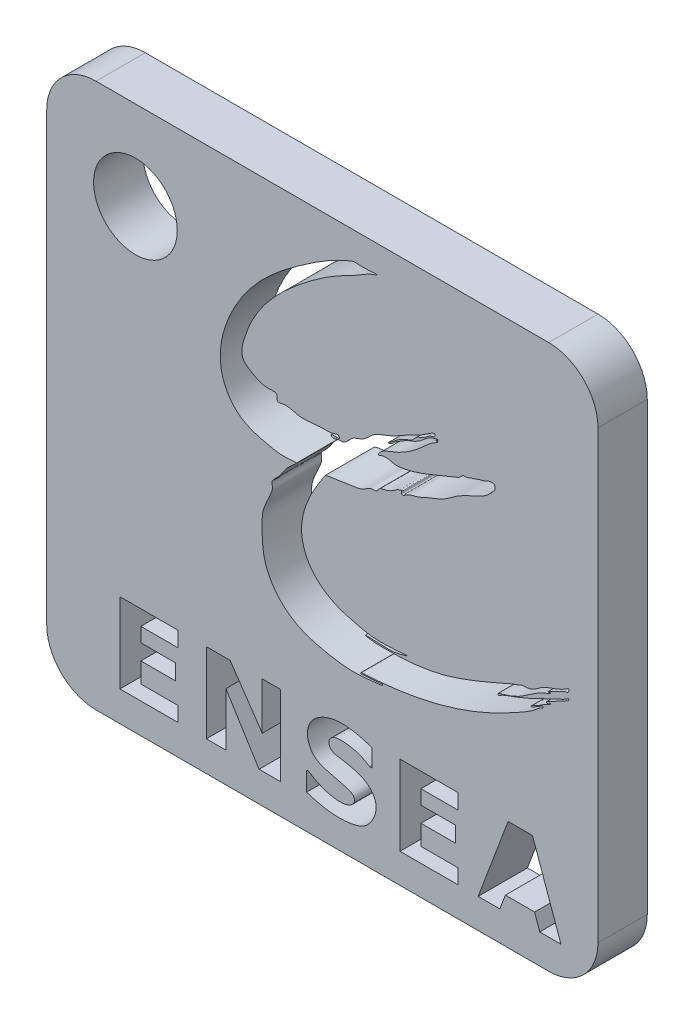
from build123d import *

# Parameters (mm, degrees)
ESQUISSE1_W        = 111.853515397
ESQUISSE1_H        = 110.489448136
ESQUISSE1_R        = 8.487246415
BOSS_EXTRU_1_DEPTH = 10
CONG_1_R           = 10


with BuildPart() as part:
    # Esquisse1 → Boss.-Extru.1 (new body)
    with BuildSketch(Plane.XY):
        with Locations((-40.07061929, 0.087618823)):
            Rectangle(ESQUISSE1_W, ESQUISSE1_H)
        with Locations((-77.997376989, 37.332342891)):
            Circle(ESQUISSE1_R, mode=Mode.SUBTRACT)
        Polygon((-81.142119991, -32.834154765), (-69.373577812, -32.834154765), (-69.373577812, -35.9209855), (-76.89772773, -35.9209855), (-76.89772773, -38.814889315), (-69.867445854, -38.814889315), (-69.867445854, -41.991744615), (-76.89772773, -41.991744615), (-76.89772773, -46.050417687), (-69.373577812, -46.050417687), (-69.373577812, -49.040016126), (-81.142119991, -49.040016126), align=None, mode=Mode.SUBTRACT)
        Polygon((-63.602729459, -32.834154765), (-58.791958965, -32.834154765), (-52.26774974, -42.390122526), (-52.26774974, -32.834154765), (-48.574180783, -32.834154765), (-48.574180783, -49.040016126), (-52.913297725, -49.040016126), (-59.643973187, -38.236108552), (-59.643973187, -49.040016126), (-63.602729459, -49.040016126), align=None, mode=Mode.SUBTRACT)
        Polygon((-24.317493797, -32.949952007), (-12.548951618, -32.949952007), (-12.548951618, -36.036782743), (-20.073101536, -36.036782743), (-20.073101536, -38.930686557), (-13.04281966, -38.930686557), (-13.04281966, -42.107541857), (-20.073101536, -42.107541857), (-20.073101536, -46.16621493), (-12.548951618, -46.16621493), (-12.548951618, -49.155813369), (-24.317493797, -49.155813369), align=None, mode=Mode.SUBTRACT)
        Polygon((-2.380831571, -32.949952007), (-8.462013051, -49.155813369), (-4.055348693, -49.155813369), (-2.933514422, -46.16621493), (3.00425704, -46.16621493), (4.031172801, -49.155813369), (8.341293256, -49.155813369), (2.56810439, -32.949952007), align=None, mode=Mode.SUBTRACT)
        with BuildLine():
            Line((-30.008433918, -33.75561302), (-30.008433918, -37.365831656))
            Line((-30.008433918, -37.365831656), (-30.440269707, -37.365831656))
            add(Edge.make_bspline(
                [(-30.440269707, -37.365831656), (-32.169583727, -36.213527846), (-34.676354356, -35.502213926), (-37.924591159, -35.675126943), (-39.003366848, -37.004461808), (-38.37222083, -38.542287073), (-36.202765447, -38.91668114), (-33.693450515, -39.313242217), (-30.724735473, -40.385038538), (-28.608765411, -43.337263363), (-29.678516982, -46.511417412), (-31.575182552, -48.552112258), (-36.158155654, -49.965655118), (-40.259045765, -49.248104373), (-43.266807199, -48.245335369)],
                knots=[0, 0, 0, 0, 0.152919806, 0.204126248, 0.234844966, 0.26786857, 0.309744694, 0.391869949, 0.468930864, 0.544718631, 0.643629321, 0.695196685, 0.754799141, 1, 1, 1, 1], degree=3))
            Line((-43.266807199, -48.245335369), (-43.266807199, -44.532632267))
            add(Edge.make_bspline(
                [(-30.008433918, -33.75561302), (-32.644971309, -32.896452561), (-37.113590856, -31.754708493), (-42.138335473, -34.399521694), (-43.535120697, -37.913361146), (-42.292785158, -41.310277563), (-39.021126972, -42.472622706), (-36.464431129, -43.059062316), (-34.542927456, -43.499377192), (-33.418874665, -44.394863071), (-33.663521479, -45.581320465), (-34.907541611, -46.47076973), (-37.020426645, -46.661102185), (-39.641294731, -46.097511522), (-41.6577397, -45.143903497), (-42.756878285, -44.40189889), (-43.233639361, -44.300144577), (-43.266807199, -44.532632267)],
                knots=[0, 0, 0, 0, 0.213304767, 0.332543217, 0.387996487, 0.489669263, 0.562609108, 0.640595189, 0.690512906, 0.712560948, 0.740191541, 0.766735411, 0.824594443, 0.89393054, 0.970764374, 0.987194069, 1, 1, 1, 1], degree=3))
        make_face(mode=Mode.SUBTRACT)
        with BuildLine():
            add(Edge.make_bspline(
                [(-39.530369768, 9.269979086), (-41.764765029, 5.874407139), (-45.860779637, -0.761335503), (-42.417117096, -9.733498384), (-37.275522095, -12.629428317), (-32.089839444, -13.853238596), (-29.505039904, -14.788782297), (-21.662573448, -13.843686332), (-25.231217847, -14.747799462), (-26.680040514, -14.935000156), (-32.801837365, -14.485113177), (-29.256336345, -15.128140462), (-27.446815334, -15.006625576), (-24.323804696, -15.099927022), (-20.235081917, -14.731098778), (-13.014530684, -13.509467381), (-3.827981132, -9.355680968), (-1.617384759, -8.368929669), (-0.344098425, -7.997869107), (0.259083652, -7.613669991), (1.020890674, -7.52457726), (2.719856947, -7.572626006), (4.129386966, -5.800961551), (7.257643118, -4.902175355), (8.783407265, -4.208850215), (9.974047382, -3.393151127), (9.949939867, -4.29890556), (9.153125834, -4.258452217), (7.891066291, -5.131654397), (6.977283966, -5.347199457), (5.647934819, -6.088269731), (5.993991935, -6.190652233), (6.327358642, -5.870859653), (6.185259222, -6.119206356), (6.124387335, -6.219259629), (6.121678474, -6.223699904)],
                knots=[0, 0, 0, 0, 0.034118173, 0.050236448, 0.068967481, 0.073500141, 0.095563045, 0.104190877, 0.107921759, 0.116908237, 0.126964302, 0.130310205, 0.137621374, 0.144820214, 0.154992728, 0.171421939, 0.207781336, 0.216895984, 0.219190241, 0.229442387, 0.232264538, 0.246130236, 0.386672642, 0.489153724, 0.601852187, 0.608768219, 0.628383974, 0.656973958, 0.68694343, 0.800374789, 0.80697629, 0.814481946, 0.827884702, 0.837106078, 0.837535097, 0.837535097, 0.837535097, 0.837535097], degree=3))
            add(Edge.make_bspline(
                [(6.121678474, -6.223699904), (1.667784898, -7.833837416), (1.376736635, -10.049704589), (-4.606405535, -11.434910949), (-4.337530824, -11.803460132), (-3.993284401, -11.601097422), (-3.266500698, -11.151659181), (-0.897256077, -10.373749193), (2.50832682, -8.947152193), (6.531114185, -6.940263823), (8.619238405, -6.065459206), (9.952071576, -5.174315264), (9.934790663, -5.721267892), (9.504012738, -5.722831982), (9.088304235, -6.150092492), (8.197239347, -6.382310466), (7.246527244, -7.09897802), (6.192254335, -7.526607447), (5.674306731, -7.874923979), (5.252108746, -8.077896653), (5.603664754, -8.349137181), (5.799812025, -8.059304926), (6.036273471, -7.879173164), (6.327896859, -8.088367728), (5.926764672, -8.14933822), (5.68779217, -8.407177482), (4.975026738, -8.661025351), (4.122819201, -9.324230734), (3.11461704, -9.864582576), (2.4686699, -10.103888072), (2.207262032, -10.441948244), (2.880257392, -10.340189753), (3.175932504, -9.886077645), (4.032966994, -9.639447735), (4.366610929, -9.21743544), (4.777713824, -9.203327615), (4.666521, -9.55380476), (4.240323075, -9.622065194), (3.745461727, -10.050731885), (2.401265537, -11.223549501), (-1.879401239, -13.677868463), (-11.693481708, -18.634763787), (-22.748652637, -21.066859644), (-30.476666566, -21.59307887), (-32.012888439, -21.659814655), (-32.180298502, -21.691462882), (-32.387885351, -21.847601114), (-31.985617547, -21.987844286), (-31.540916454, -21.802141493), (-30.891698554, -21.838913627), (-30.647718429, -21.810762074)],
                knots=[0, 0, 0, 0, 0.134847579, 0.143034237, 0.144601639, 0.148638772, 0.154180377, 0.178067515, 0.234677611, 0.292201023, 0.330745501, 0.333193175, 0.337239427, 0.34163035, 0.346584802, 0.358071859, 0.373748347, 0.389768442, 0.396912852, 0.399366253, 0.402749079, 0.40598643, 0.410304005, 0.412055835, 0.415102654, 0.419095224, 0.426513149, 0.440578697, 0.458947906, 0.465949143, 0.46750081, 0.470952025, 0.480463688, 0.491216585, 0.499184075, 0.500837468, 0.502285256, 0.509315764, 0.515195501, 0.525664095, 0.573905162, 0.691976912, 0.92332858, 0.972552013, 0.974530944, 0.977935359, 0.979470166, 0.981332426, 0.988581693, 1, 1, 1, 1], degree=3))
            add(Edge.make_bspline(
                [(-30.647718429, -21.810762074), (-30.635929874, -21.821607545), (-28.855982141, -21.736045008), (-27.949431298, -21.562654224), (-27.792186672, -21.643211758), (-27.901529138, -21.882780872), (-27.995793894, -21.870862347), (-28.146044576, -21.870862347)],
                knots=[0, 0, 0, 0, 0.789100761, 0.825841685, 0.866784773, 0.917493908, 1, 1, 1, 1], degree=3))
            add(Edge.make_bspline(
                [(-28.146044576, -21.870862347), (-30.159622812, -22.110076046), (-33.366304636, -22.550706567), (-39.68206804, -21.746955402), (-46.819813376, -20.048328147), (-52.347850621, -12.779636555), (-52.290221316, -7.190251777), (-52.276750894, -2.596901918), (-50.713181424, -0.22375106), (-50.085651286, 1.878504554), (-50.549279448, 2.908963282), (-49.074552086, 4.097988899), (-47.884735717, 5.899227413), (-46.881541325, 7.238743692), (-44.908556078, 8.740299019), (-48.375822943, 8.301622529), (-51.044072222, 8.9022687), (-56.425937654, 10.122923177), (-63.132886846, 18.028050018), (-57.414442751, 33.779518499), (-45.658317117, 43.19219591), (-37.647317486, 48.308878357), (-33.614834178, 49.848064842), (-32.51702159, 49.698838657), (-31.273209466, 49.720017971), (-28.078032516, 49.949183724), (-30.617050338, 49.245156684), (-32.572861861, 47.852849456), (-37.36107261, 45.613636215), (-44.067631333, 41.041953115), (-51.608832009, 34.340727374), (-55.489089777, 27.354939), (-56.89760363, 21.428372051), (-53.797963957, 19.604145319), (-51.98791967, 18.575141842), (-49.175609501, 19.01580467), (-49.314064693, 18.058129222), (-49.219801424, 17.25361145), (-47.082252149, 17.942645407), (-44.658182266, 16.658796455), (-40.879986338, 17.503165018), (-38.40739904, 17.185269039), (-36.84634226, 17.882164323), (-36.403652161, 17.118691211), (-37.428530397, 17.198715226), (-38.562364665, 17.188352447), (-37.785143621, 16.432820979), (-37.017788618, 17.069477419), (-35.396515777, 16.709647913), (-34.293100102, 18.898112499), (-31.699128891, 19.229412669), (-29.730842888, 21.812619556), (-26.067465765, 22.628346138), (-22.308978273, 25.237387054), (-20.210827577, 25.826933657), (-17.061395321, 28.200791647), (-17.318732728, 26.990758701), (-18.229364896, 27.010182807), (-18.96702457, 26.225832637), (-19.937817523, 25.706259327), (-21.056119284, 25.339560899), (-21.743441022, 24.244241708), (-23.285991718, 23.818027395), (-24.890682253, 22.906892038), (-25.704082388, 22.137935042), (-27.154542208, 21.203977401), (-25.809684653, 21.665515584), (-25.387947764, 22.284846982), (-24.162029173, 22.937644089), (-23.056168152, 23.758262118), (-21.459888737, 24.252011789), (-19.408252983, 25.462043274), (-18.479190889, 26.762381849), (-16.489895986, 27.077271959), (-16.758995108, 26.773005362), (-16.764545119, 26.844855159), (-17.017629248, 26.728383727)],
                knots=[0, 0, 0, 0, 0.026687041, 0.041758511, 0.083493474, 0.118973002, 0.150540371, 0.156597534, 0.176994959, 0.18017269, 0.185825157, 0.191479594, 0.201603433, 0.213817923, 0.218106659, 0.223795932, 0.242243458, 0.266099554, 0.288781538, 0.369710272, 0.440444573, 0.490023006, 0.491708173, 0.496504241, 0.503315345, 0.512757585, 0.517466541, 0.527117388, 0.549027526, 0.582504712, 0.63508691, 0.675369094, 0.692163791, 0.702025976, 0.717110337, 0.724426756, 0.726291893, 0.728748425, 0.733278045, 0.748050913, 0.765920834, 0.779574845, 0.782783307, 0.784336954, 0.788151912, 0.791966871, 0.79347413, 0.798862712, 0.802060091, 0.813838189, 0.823241002, 0.834393423, 0.85328146, 0.871386034, 0.888313364, 0.896675766, 0.89777436, 0.902184864, 0.905808952, 0.91165869, 0.916425933, 0.920642695, 0.927542642, 0.936656222, 0.942844494, 0.946607064, 0.949757772, 0.954208113, 0.957935126, 0.967061389, 0.972245786, 0.979627044, 0.996876113, 0.997505843, 0.998262685, 1, 1, 1, 1], degree=3))
            add(Edge.make_bspline(
                [(-17.017629248, 26.728383727), (-17.048003124, 26.585931941), (-16.840467381, 26.696460359), (-16.541805373, 26.669003316), (-16.853300298, 26.401807724), (-17.21583092, 26.165730075), (-18.10491528, 25.677559069), (-19.261178559, 24.583746022), (-21.567217994, 22.579086643), (-24.60239306, 20.494966011), (-28.031920814, 19.624218962), (-28.663784882, 18.494822078), (-28.751785644, 18.348918197), (-28.371755268, 18.258881688), (-28.093637739, 18.531805834), (-27.441064395, 18.611197471), (-26.720018234, 18.655092347), (-25.820411164, 18.321023767), (-24.81952067, 18.245190532), (-22.570899215, 18.568366011), (-19.718238553, 19.470304111), (-16.169580889, 20.969531918), (-13.659805993, 21.941777486), (-12.020532593, 22.668821026), (-11.579249085, 23.393343832), (-10.770453147, 23.190643308), (-10.084148735, 23.639487119), (-9.115622134, 23.811000064), (-8.327643878, 24.245133721), (-7.361501668, 24.358083362), (-6.662862414, 24.827723004), (-5.904258411, 24.996774328), (-5.116756382, 24.954700982), (-4.891472485, 24.099995224), (-5.649979399, 23.259351401), (-6.816094837, 21.957612971), (-9.471240768, 20.683604996), (-12.597885705, 19.37989576), (-15.465203847, 16.86653745), (-18.449441852, 16.020002625), (-20.934915236, 14.672713322), (-22.53807921, 14.61130085), (-23.80988541, 13.458083754), (-24.099612785, 14.102586226), (-23.603161907, 14.60533614), (-24.712714744, 14.230275215), (-25.2603819, 13.85574263), (-26.271081443, 13.138374391), (-27.414611428, 12.805459389), (-28.593215871, 12.590677984), (-28.990855107, 11.5700116), (-29.931756466, 11.784441131), (-30.909539668, 11.335826926), (-32.140853449, 10.397368145), (-34.288791858, 10.260640461), (-36.770472695, 9.680043749), (-38.589980979, 9.631514571), (-39.530369768, 9.269979086)],
                knots=[0, 0, 0, 0, 0.003834771, 0.005625769, 0.008650413, 0.013337213, 0.025484996, 0.043793879, 0.074034413, 0.138519412, 0.186487406, 0.188035725, 0.189270321, 0.191768902, 0.197818485, 0.204073543, 0.21530722, 0.224788642, 0.239449454, 0.252378597, 0.309642938, 0.350812124, 0.396294991, 0.411558776, 0.416284588, 0.425569842, 0.43728448, 0.446181137, 0.462020104, 0.470349452, 0.482049517, 0.492444261, 0.500051468, 0.507957674, 0.519114075, 0.539936082, 0.57420713, 0.626741522, 0.66709193, 0.713692614, 0.742757768, 0.767935224, 0.78126626, 0.7848311, 0.790075173, 0.797680908, 0.809788701, 0.82317486, 0.840569523, 0.856115471, 0.863527385, 0.876385841, 0.884884293, 0.903946939, 0.932867387, 0.962688937, 1, 1, 1, 1], degree=3))
        make_face(mode=Mode.SUBTRACT)
    extrude(amount=BOSS_EXTRU_1_DEPTH)

    # Congé1
    cong_1_edges = [part.edges().sort_by_distance(p)[0] for p in [
        (15.856138408, -55.157105245, 5),
        (-95.997376989, -55.157105245, 5),
        (-95.997376989, 55.332342891, 5),
        (15.856138408, 55.332342891, 5),
    ]]
    fillet(cong_1_edges, radius=CONG_1_R)


solid = part.part
